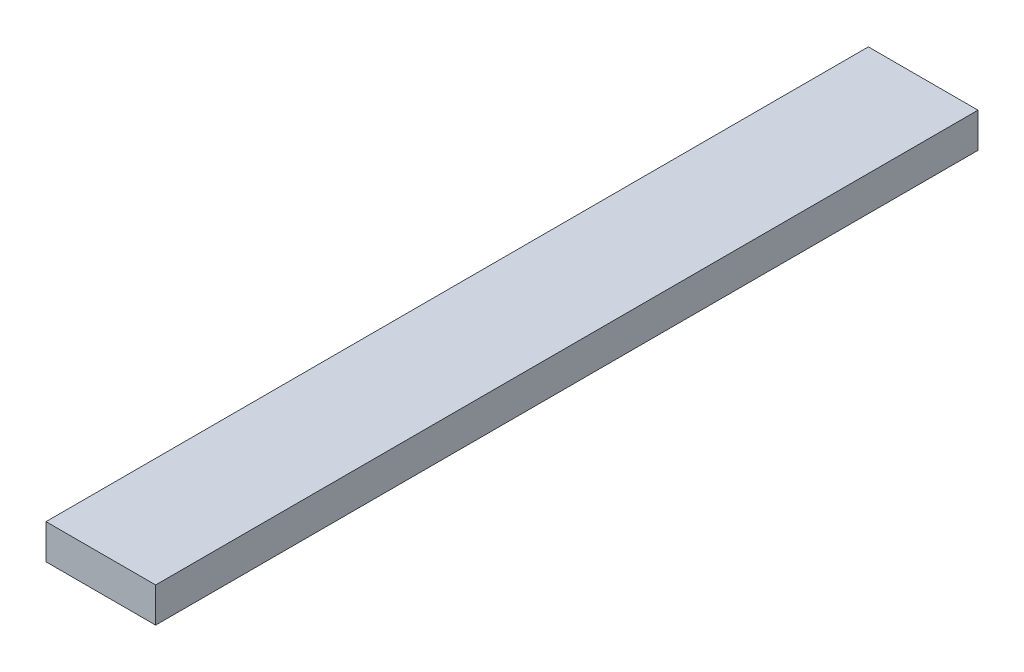
from build123d import *

# Parameters (mm, degrees)
SKETCH1_W           = 20
SKETCH1_H           = 150
BOSS_EXTRUDE1_DEPTH = 6.35


with BuildPart() as part:
    # Sketch1 → Boss-Extrude1 (new body)
    with BuildSketch(Plane(origin=(0, 0, 0), x_dir=(1, 0, 0), z_dir=(0, 1, 0))):
        with Locations((10, 75)):
            Rectangle(SKETCH1_W, SKETCH1_H)
    extrude(amount=BOSS_EXTRUDE1_DEPTH)


solid = part.part
